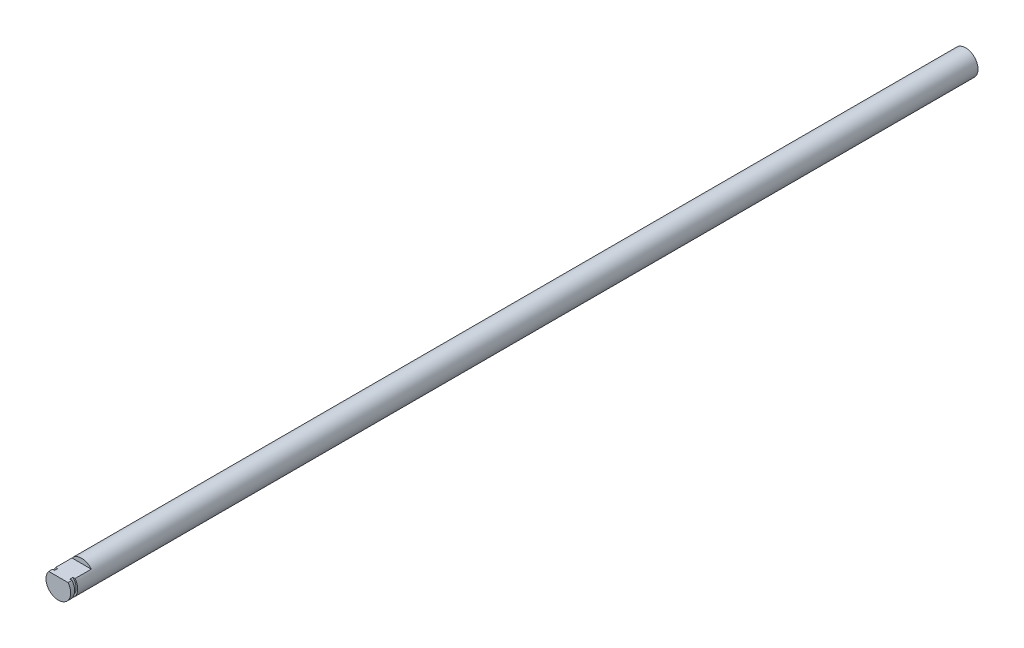
from build123d import *

# Parameters (mm, degrees)
SKETCH1_R           = 4
BOSS_EXTRUDE1_DEPTH = 325
CUT_EXTRUDE1_DEPTH  = 7.5
SKETCH3_R           = 4
SKETCH3_R_2         = 3.5
CUT_EXTRUDE2_DEPTH  = 1
SKETCH5_R           = 4
CUT_EXTRUDE3_DEPTH  = 65
SKETCH6_R           = 4
BOSS_EXTRUDE2_DEPTH = 13
SKETCH7_R           = 4
BOSS_EXTRUDE3_DEPTH = 10
SKETCH8_R           = 4
BOSS_EXTRUDE4_DEPTH = 40
SKETCH9_R           = 4
CUT_EXTRUDE4_DEPTH  = 30


with BuildPart() as part:
    # Sketch1 → Boss-Extrude1 (new body)
    with BuildSketch(Plane.XY):
        Circle(SKETCH1_R)
    extrude(amount=BOSS_EXTRUDE1_DEPTH)

    # Sketch2 → Cut-Extrude1 (cut)
    with BuildSketch(Plane.XY.offset(325)):
        with BuildLine():
            Line((3.122498999, 2.5), (-3.122498999, 2.5))
            ThreePointArc((-3.122498999, 2.5), (0, 4), (3.122498999, 2.5))
        make_face()
    extrude(amount=-CUT_EXTRUDE1_DEPTH, mode=Mode.SUBTRACT)

    # Sketch3 → Cut-Extrude2 (cut)
    with BuildSketch(Plane.XY.offset(323.75)):
        Circle(SKETCH3_R)
        Circle(SKETCH3_R_2, mode=Mode.SUBTRACT)
    extrude(amount=-CUT_EXTRUDE2_DEPTH, mode=Mode.SUBTRACT)

    # Sketch5 → Cut-Extrude3 (cut)
    with BuildSketch(Plane(origin=(0, 0, 0), x_dir=(-1, 0, 0), z_dir=(0, 0, -1))):
        Circle(SKETCH5_R)
    extrude(amount=-CUT_EXTRUDE3_DEPTH, mode=Mode.SUBTRACT)

    # Sketch6 → Boss-Extrude2 (add)
    with BuildSketch(Plane(origin=(0, 0, 65), x_dir=(-1, 0, 0), z_dir=(0, 0, -1))):
        Circle(SKETCH6_R)
    extrude(amount=BOSS_EXTRUDE2_DEPTH)

    # Sketch7 → Boss-Extrude3 (add)
    with BuildSketch(Plane(origin=(0, 0, 52), x_dir=(-1, 0, 0), z_dir=(0, 0, -1))):
        Circle(SKETCH7_R)
    extrude(amount=BOSS_EXTRUDE3_DEPTH)

    # Sketch8 → Boss-Extrude4 (add)
    with BuildSketch(Plane(origin=(0, 0, 42), x_dir=(-1, 0, 0), z_dir=(0, 0, -1))):
        Circle(SKETCH8_R)
    extrude(amount=BOSS_EXTRUDE4_DEPTH)

    # Sketch9 → Cut-Extrude4 (cut)
    with BuildSketch(Plane(origin=(0, 0, 2), x_dir=(-1, 0, 0), z_dir=(0, 0, -1))):
        Circle(SKETCH9_R)
    extrude(amount=-CUT_EXTRUDE4_DEPTH, mode=Mode.SUBTRACT)


solid = part.part
